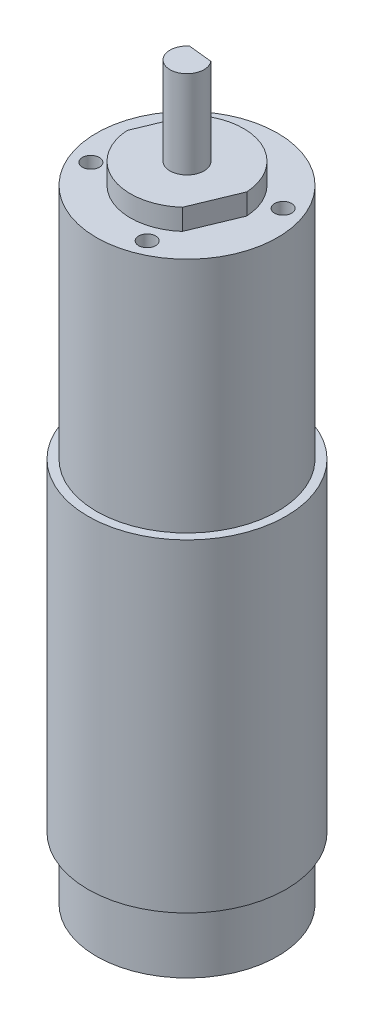
from build123d import *

# Parameters (mm, degrees)
SKETCH1_R           = 17.5
BOSS_EXTRUDE1_DEPTH = 57.1
SKETCH2_R           = 16
BOSS_EXTRUDE2_DEPTH = 11
SKETCH3_R           = 16
BOSS_EXTRUDE3_DEPTH = 41.9
SKETCH4_R           = 1.5
CUT_EXTRUDE2_DEPTH  = 15
BOSS_EXTRUDE5_DEPTH = 3.7
SKETCH7_R           = 3
BOSS_EXTRUDE6_DEPTH = 15.5
CUT_EXTRUDE3_DEPTH  = 10


with BuildPart() as part:
    # Sketch1 → Boss-Extrude1 (new body)
    with BuildSketch(Plane(origin=(0, 0, 0), x_dir=(1, 0, 0), z_dir=(0, 1, 0))):
        Circle(SKETCH1_R)
    extrude(amount=BOSS_EXTRUDE1_DEPTH)

    # Sketch2 → Boss-Extrude2 (add)
    with BuildSketch(Plane.XZ):
        Circle(SKETCH2_R)
    extrude(amount=BOSS_EXTRUDE2_DEPTH)

    # Sketch3 → Boss-Extrude3 (add)
    with BuildSketch(Plane(origin=(0, 57.1, 0), x_dir=(1, 0, 0), z_dir=(0, 1, 0))):
        Circle(SKETCH3_R)
    extrude(amount=BOSS_EXTRUDE3_DEPTH)

    # Sketch4 → Cut-Extrude2 (cut)
    with BuildSketch(Plane(origin=(0, 99, 0), x_dir=(1, 0, 0), z_dir=(0, 1, 0))):
        with Locations((12.012324504, 4.970317898)):
            Circle(SKETCH4_R)
        with Locations((-4.970317898, 12.012324504)):
            Circle(SKETCH4_R)
        with Locations((-12.012324504, -4.970317898)):
            Circle(SKETCH4_R)
        with Locations((4.970317898, -12.012324504)):
            Circle(SKETCH4_R)
    extrude(amount=-CUT_EXTRUDE2_DEPTH, mode=Mode.SUBTRACT)

    # Sketch6 → Boss-Extrude5 (add)
    with BuildSketch(Plane(origin=(0, 99, 0), x_dir=(1, 0, 0), z_dir=(0, 1, 0))):
        with BuildLine():
            Line((-9.983215116, -0.579151054), (-6.643996337, 7.473774995))
            ThreePointArc((-6.643996337, 7.473774995), (3.830346634, 9.237339696), (9.983215116, 0.579151054))
            Line((9.983215116, 0.579151054), (6.643996337, -7.473774995))
            ThreePointArc((6.643996337, -7.473774995), (-3.830346634, -9.237339696), (-9.983215116, -0.579151054))
        make_face()
    extrude(amount=BOSS_EXTRUDE5_DEPTH)

    # Sketch7 → Boss-Extrude6 (add)
    with BuildSketch(Plane(origin=(0, 102.7, 0), x_dir=(1, 0, 0), z_dir=(0, 1, 0))):
        Circle(SKETCH7_R)
    extrude(amount=BOSS_EXTRUDE6_DEPTH)

    # Sketch8 → Cut-Extrude3 (cut)
    with BuildSketch(Plane(origin=(0, 118.2, 0), x_dir=(1, 0, 0), z_dir=(0, 1, 0))):
        with BuildLine():
            Line((-1.883851207, 2.334760079), (2.334760079, 1.883851207))
            ThreePointArc((2.334760079, 1.883851207), (0.318840721, 2.983008648), (-1.883851207, 2.334760079))
        make_face()
    extrude(amount=-CUT_EXTRUDE3_DEPTH, mode=Mode.SUBTRACT)


solid = part.part
